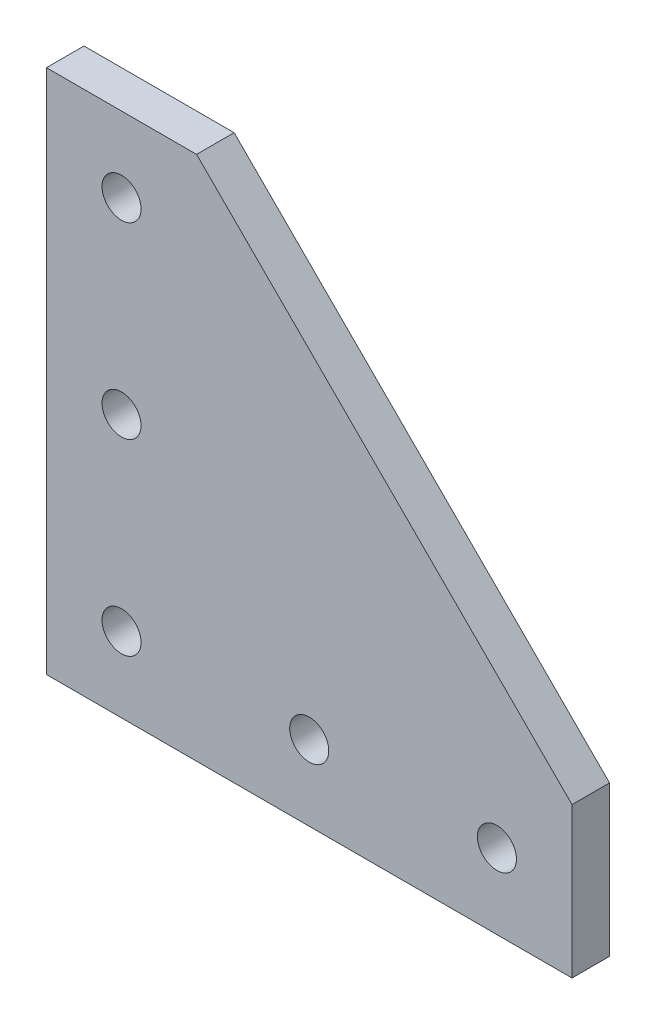
from build123d import *

# Parameters (mm, degrees)
SKETCH1_R           = 3.302
BOSS_EXTRUDE1_DEPTH = 6.35


with BuildPart() as part:
    # Sketch1 → Boss-Extrude1 (new body)
    with BuildSketch(Plane.XY):
        Polygon((88.9, 0), (0, 0), (0, 88.9), (25.4, 88.9), (88.9, 25.4), align=None)
        with Locations((76.2, 12.7)):
            Circle(SKETCH1_R, mode=Mode.SUBTRACT)
        with Locations((44.45, 12.7)):
            Circle(SKETCH1_R, mode=Mode.SUBTRACT)
        with Locations((12.7, 76.2)):
            Circle(SKETCH1_R, mode=Mode.SUBTRACT)
        with Locations((12.7, 44.45)):
            Circle(SKETCH1_R, mode=Mode.SUBTRACT)
        with Locations((12.7, 12.7)):
            Circle(SKETCH1_R, mode=Mode.SUBTRACT)
    extrude(amount=BOSS_EXTRUDE1_DEPTH)


solid = part.part
